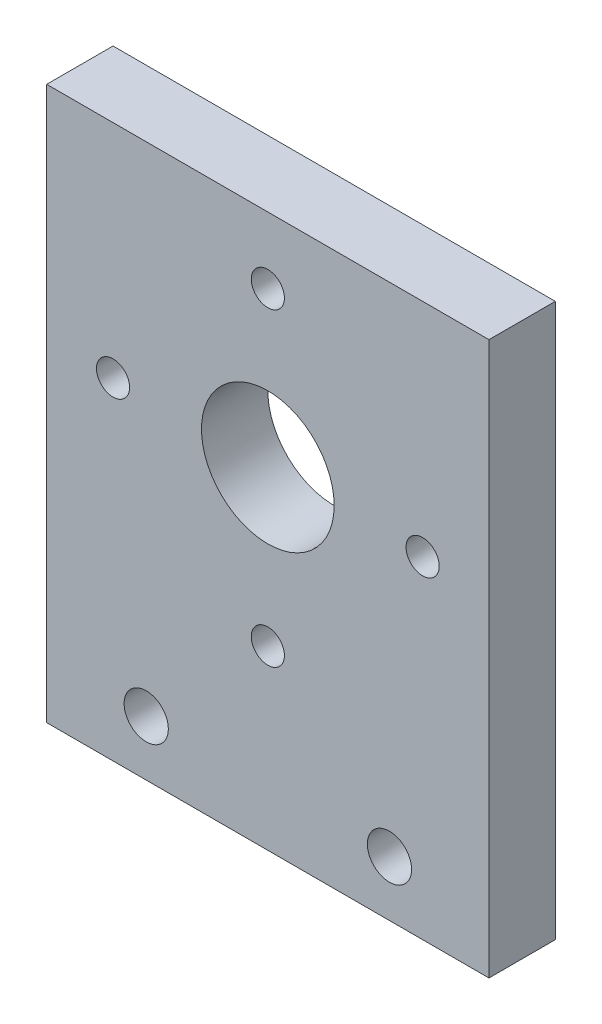
from build123d import *

# Parameters (mm, degrees)
SKETCH1_W           = 20
SKETCH1_H           = 25
SKETCH1_R           = 0.75
SKETCH1_R_2         = 1
BOSS_EXTRUDE1_DEPTH = 3


with BuildPart() as part:
    # Sketch1 → Boss-Extrude1 (new body)
    with BuildSketch(Plane.XY):
        with Locations((10, -12.5)):
            Rectangle(SKETCH1_W, SKETCH1_H)
        with Locations((10, -17)):
            Circle(SKETCH1_R, mode=Mode.SUBTRACT)
        with Locations((3, -10)):
            Circle(SKETCH1_R, mode=Mode.SUBTRACT)
        with BuildLine():
            ThreePointArc((10, -7), (12.121320344, -7.878679656), (13, -10))
            ThreePointArc((13, -10), (12.121320344, -12.121320344), (10, -13))
            ThreePointArc((10, -13), (7.878679656, -12.121320344), (7, -10))
            ThreePointArc((7, -10), (7.878679656, -7.878679656), (10, -7))
        make_face(mode=Mode.SUBTRACT)
        with Locations((10, -3)):
            Circle(SKETCH1_R, mode=Mode.SUBTRACT)
        with Locations((17, -10)):
            Circle(SKETCH1_R, mode=Mode.SUBTRACT)
        with Locations((4.5, -22.5)):
            Circle(SKETCH1_R_2, mode=Mode.SUBTRACT)
        with Locations((15.5, -22.5)):
            Circle(SKETCH1_R_2, mode=Mode.SUBTRACT)
    extrude(amount=BOSS_EXTRUDE1_DEPTH)


solid = part.part
